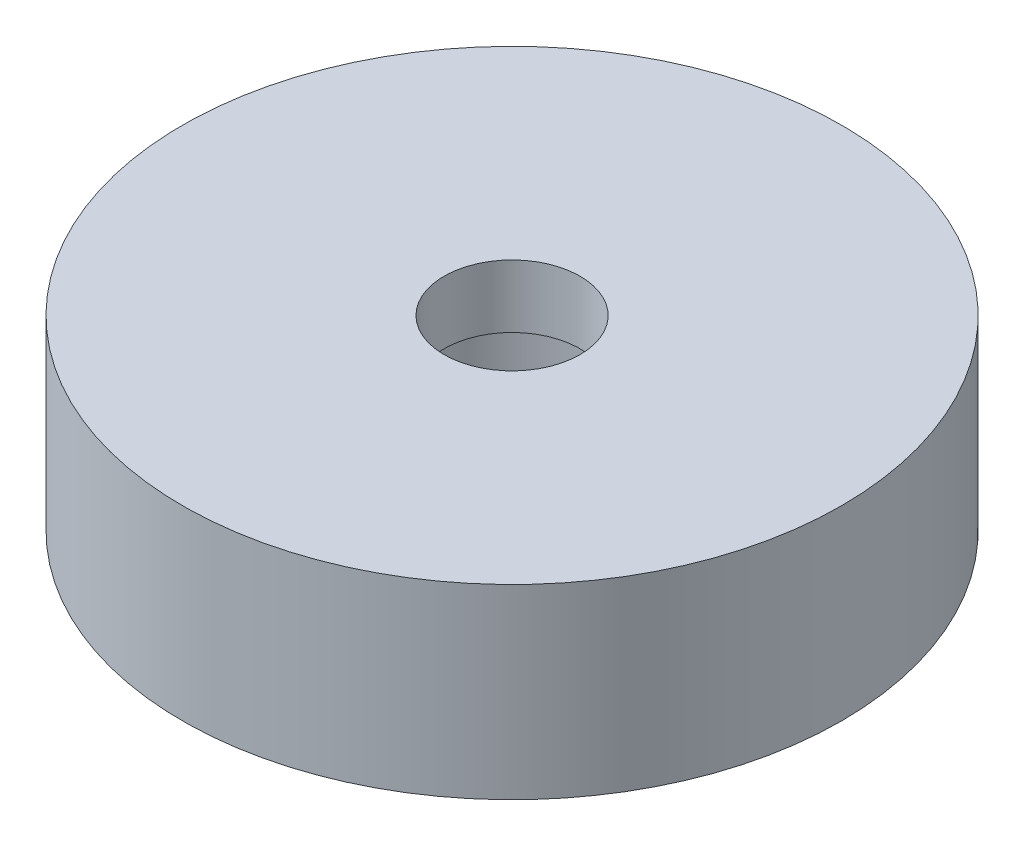
from build123d import *


with BuildPart() as part:
    # Sketch1 → Revolve1 (revolve)
    with BuildSketch(Plane.XY):
        Polygon((2.8, 0), (2.8, 3), (1.65, 3), (1.65, 4.525), (8, 4.525), (8, 0), align=None)
    revolve(axis=Axis((0, -251.458428202, 0), (0, 1, 0)))


solid = part.part
